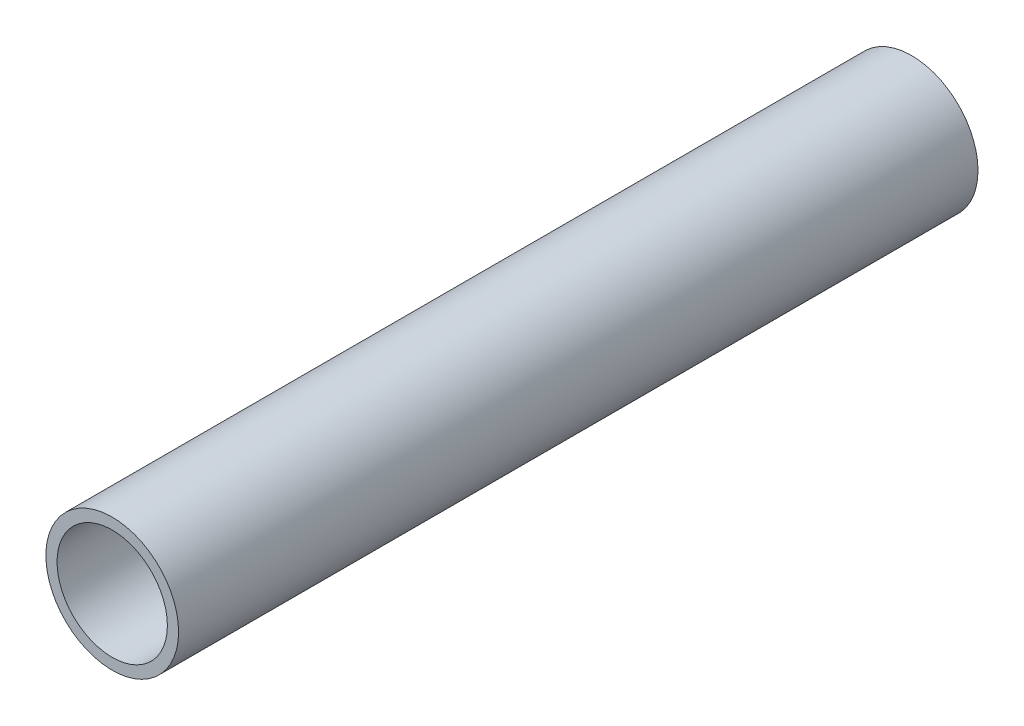
from build123d import *

# Parameters (mm, degrees)
SKETCH1_R           = 21.082
SKETCH1_R_2         = 17.526
EXTRUDE_THIN1_DEPTH = 127


with BuildPart() as part:
    # Sketch1 → Extrude-Thin1 (new body, symmetric)
    with BuildSketch(Plane.XY):
        Circle(SKETCH1_R)
        Circle(SKETCH1_R_2, mode=Mode.SUBTRACT)
    extrude(amount=EXTRUDE_THIN1_DEPTH, both=True)


solid = part.part
